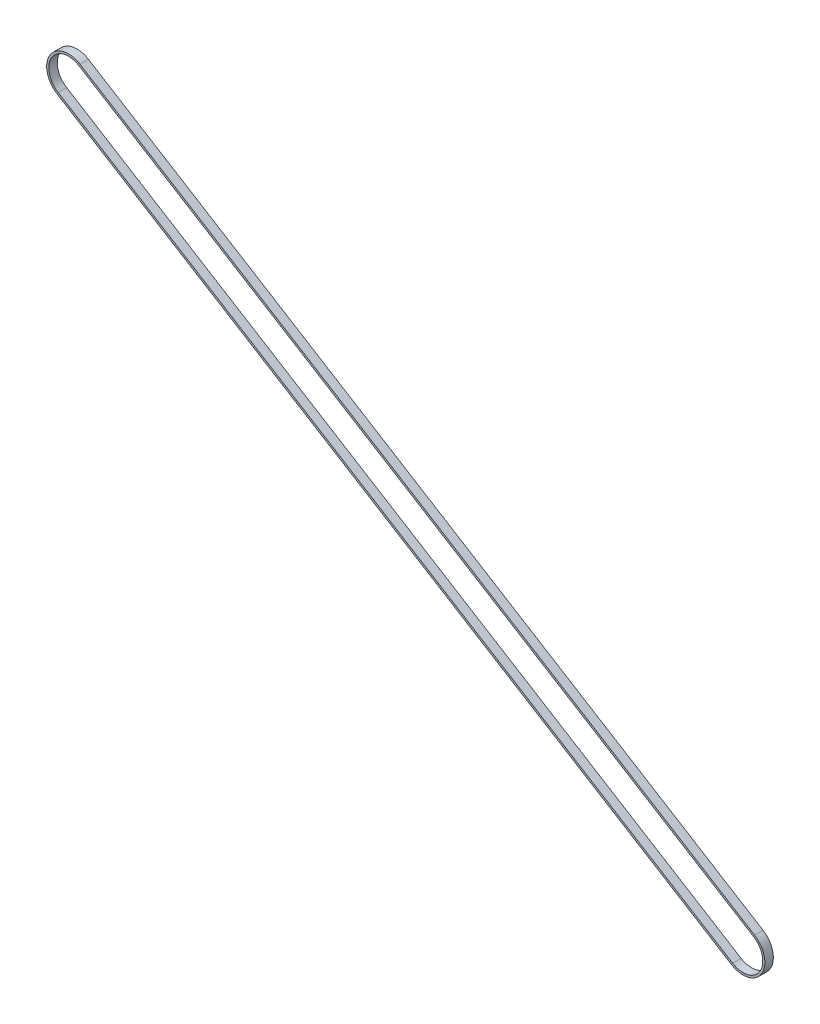
from build123d import *

# Parameters (mm, degrees)
EXTRUDE_1_DEPTH = 6


with BuildPart() as part:
    # 草图2 → 拉伸-薄壁1 (new body)
    with BuildSketch(Plane.XY):
        with BuildLine():
            Line((-469.784021129, 308.519305272), (8.135387184, 13.164007762))
            ThreePointArc((8.135387184, 13.164007762), (13.164007763, -8.135387184), (-8.135387184, -13.164007763))
            Line((-8.135387184, -13.164007763), (-486.054795496, 282.191289747))
            ThreePointArc((-486.054795496, 282.191289747), (-491.083416075, 303.490684693), (-469.784021129, 308.519305272))
        make_face()
        with BuildLine():
            Line((-470.572588546, 307.243310982), (7.346819767, 11.888013472))
            ThreePointArc((7.346819767, 11.888013472), (11.888013472, -7.346819767), (-7.346819767, -11.888013472))
            Line((-7.346819767, -11.888013472), (-485.266228079, 283.467284037))
            ThreePointArc((-485.266228079, 283.467284037), (-489.807421785, 302.702117276), (-470.572588546, 307.243310982))
        make_face(mode=Mode.SUBTRACT)
    extrude(amount=EXTRUDE_1_DEPTH)


solid = part.part
